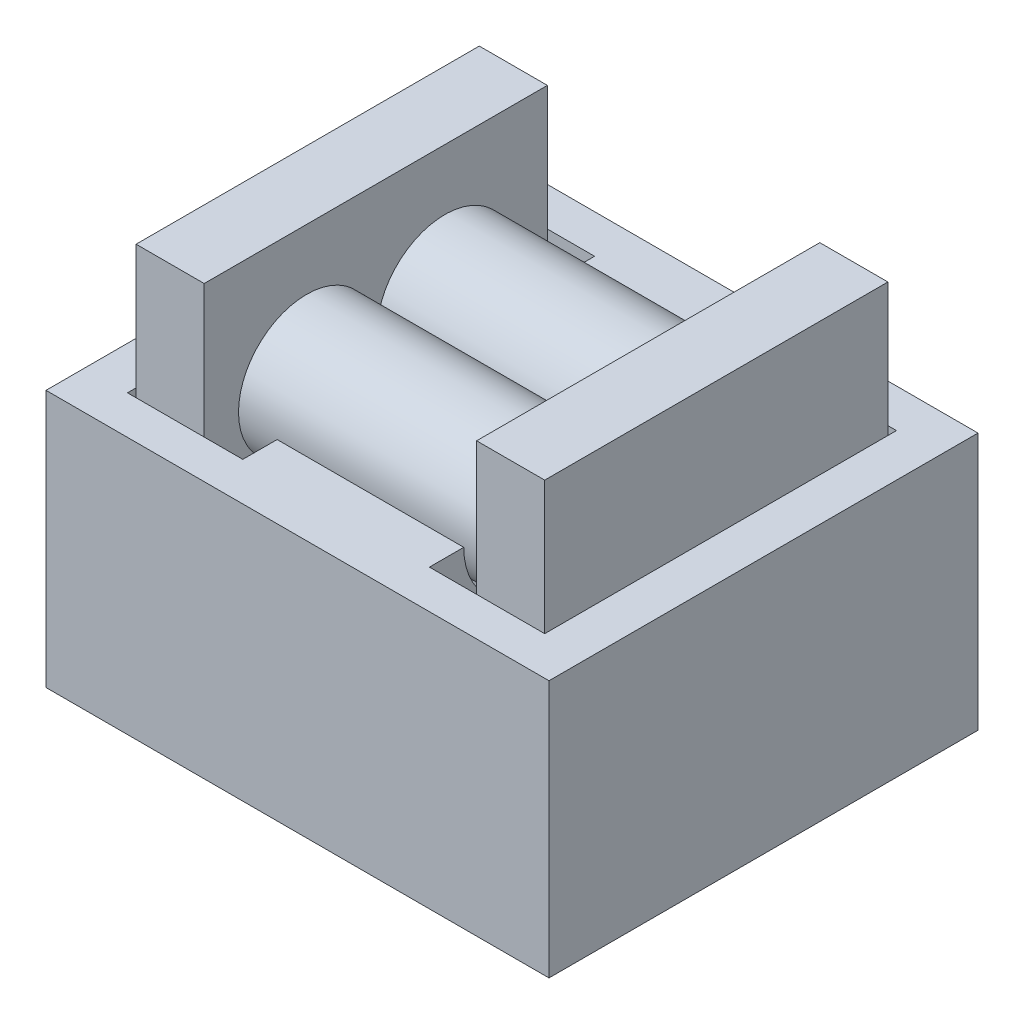
from build123d import *

# Parameters (mm, degrees)
SKETCH2_W                = 1.5875
SKETCH2_H                = 8
BOSS_EXTRUDE1_DEPTH      = 8
SKETCH3_R                = 1.5875
BOSS_EXTRUDE2_DEPTH      = 6.35
SKETCH4_W                = 8
SKETCH4_H                = 8
BOSS_EXTRUDE3_DEPTH      = 1.5875
BOSS_EXTRUDE4_DEPTH      = 2.175
BOSS_EXTRUDE4_DEPTH_BACK = 2.175
SKETCH6_W                = 11.725
SKETCH6_H                = 10
SKETCH6_W_2              = 1.7875
SKETCH6_H_2              = 8.2
BOSS_EXTRUDE5_DEPTH      = 3
SKETCH8_W                = 11.725
SKETCH8_H                = 10
SKETCH8_W_2              = 9.725
SKETCH8_H_2              = 8.2
BOSS_EXTRUDE6_DEPTH      = 2
SKETCH9_W                = 11.725
SKETCH9_H                = 10
BOSS_EXTRUDE7_DEPTH      = 1


with BuildPart() as part:
    # Sketch2 → Boss-Extrude1 (new body)
    with BuildSketch(Plane(origin=(0, 0, 0), x_dir=(1, 0, 0), z_dir=(0, 1, 0))):
        with Locations((0.79375, 4)):
            Rectangle(SKETCH2_W, SKETCH2_H)
    extrude(amount=BOSS_EXTRUDE1_DEPTH)

    # Sketch3 → Boss-Extrude2 (add)
    with BuildSketch(Plane.ZY):
        with Locations((-5.6125, 5)):
            Circle(SKETCH3_R)
        with Locations((-2.3875, 5)):
            Circle(SKETCH3_R)
    extrude(amount=BOSS_EXTRUDE2_DEPTH)

    # Sketch4 → Boss-Extrude3 (add)
    with BuildSketch(Plane.ZY.offset(6.35)):
        with Locations((-4, 4)):
            Rectangle(SKETCH4_W, SKETCH4_H)
    extrude(amount=BOSS_EXTRUDE3_DEPTH)


with BuildPart() as body_2:
    # Sketch5 → Boss-Extrude4 (new body, two sides)
    with BuildSketch(Plane.ZY.offset(3.175)) as boss_extrude4_sk:
        with BuildLine():
            Line((-7.3, 5), (-9, 5))
            Line((-9, 5), (-9, 0))
            Line((-9, 0), (1, 0))
            Line((1, 0), (1, 5))
            Line((1, 5), (-0.7, 5))
            ThreePointArc((-0.7, 5), (-2.135942353, 3.33135534), (-4, 4.502506281))
            ThreePointArc((-4, 4.502506281), (-5.864057647, 3.33135534), (-7.3, 5))
        make_face()
    extrude(amount=BOSS_EXTRUDE4_DEPTH)
    extrude(boss_extrude4_sk.sketch, amount=-BOSS_EXTRUDE4_DEPTH_BACK)

    # Sketch6 → Boss-Extrude5 (add)
    with BuildSketch(Plane.XZ):
        with Locations((-3.175, -4)):
            Rectangle(SKETCH6_W, SKETCH6_H)
        with Locations((0.79375, -4)):
            Rectangle(SKETCH6_W_2, SKETCH6_H_2, mode=Mode.SUBTRACT)
        with Locations((-7.14375, -4)):
            Rectangle(SKETCH6_W_2, SKETCH6_H_2, mode=Mode.SUBTRACT)
    extrude(amount=-BOSS_EXTRUDE5_DEPTH)

    # Sketch8 → Boss-Extrude6 (add)
    with BuildSketch(Plane(origin=(0, 3, 0), x_dir=(1, 0, 0), z_dir=(0, 1, 0))):
        with Locations((-3.175, 4)):
            Rectangle(SKETCH8_W, SKETCH8_H)
        with Locations((-3.175, 4)):
            Rectangle(SKETCH8_W_2, SKETCH8_H_2, mode=Mode.SUBTRACT)
    extrude(amount=BOSS_EXTRUDE6_DEPTH)


with BuildPart() as body_3:
    # Sketch9 → Boss-Extrude7 (new body)
    with BuildSketch(Plane.XZ):
        with Locations((-3.175, -4)):
            Rectangle(SKETCH9_W, SKETCH9_H)
    extrude(amount=BOSS_EXTRUDE7_DEPTH)


with BuildPart() as body_2_1:
    add(body_2.part)

    # Combine1: union body 3
    add(body_3.part)


solid = Compound([part.part, body_2_1.part])
